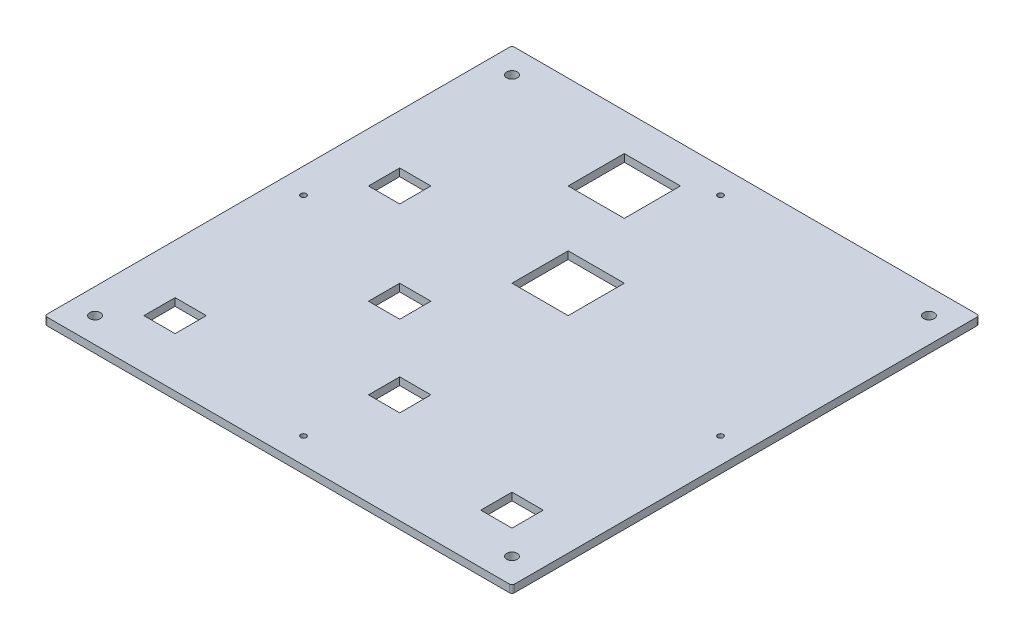
from build123d import *

# Parameters (mm, degrees)
ESQUISSE2_W             = 185
ESQUISSE2_H             = 185
BOSS_EXTRU_1_DEPTH      = 3
ESQUISSE3_W             = 185
ESQUISSE3_H             = 185
ESQUISSE3_W_2           = 155.54
ESQUISSE3_H_2           = 155.54
BOSS_EXTRU_2_DEPTH      = 40
BOSS_EXTRU_3_DEPTH      = 20
ENL_V_MAT_EXTRU_1_REACH = 5
ESQUISSE5_W             = 22.22
ESQUISSE5_H             = 22.22
ESQUISSE5_W_2           = 12.35
ESQUISSE5_H_2           = 12.35
CONG_1_R                = 1
ESQUISSE6_R             = 1.1
ENL_V_MAT_EXTRU_2_DEPTH = 44
ESQUISSE7_R             = 2.1
ENL_V_MAT_EXTRU_3_DEPTH = 44
ESQUISSE8_W             = 226.485362767
ESQUISSE8_H             = 93.740227698
ENL_V_MAT_EXTRU_4_DEPTH = 186


with BuildPart() as part:
    # Esquisse2 → Boss.-Extru.1 (new body)
    with BuildSketch(Plane(origin=(0, 0, 0), x_dir=(1, 0, 0), z_dir=(0, 1, 0))):
        Rectangle(ESQUISSE2_W, ESQUISSE2_H)
    extrude(amount=-BOSS_EXTRU_1_DEPTH)

    # Esquisse3 → Boss.-Extru.2 (add)
    with BuildSketch(Plane(origin=(0, 0, 0), x_dir=(1, 0, 0), z_dir=(0, 1, 0))):
        Rectangle(ESQUISSE3_W, ESQUISSE3_H)
        Rectangle(ESQUISSE3_W_2, ESQUISSE3_H_2, mode=Mode.SUBTRACT)
    extrude(amount=BOSS_EXTRU_2_DEPTH)

    # Esquisse4 → Boss.-Extru.3 (add)
    with BuildSketch(Plane(origin=(0, 0, 0), x_dir=(1, 0, 0), z_dir=(0, 1, 0))):
        Polygon((-55.55, 77.77), (-33.33, 77.77), (-33.33, 55.55), (11.11, 55.55), (11.11, 33.33), (-11.11, 33.33), (-11.11, -11.11), (-33.33, -11.11), (-33.33, -55.55), (-55.55, -55.55), (-55.55, 11.11), (-33.33, 11.11), (-33.33, 33.33), (-55.55, 33.33), align=None)
        Polygon((33.33, 55.55), (55.55, 55.55), (55.55, -55.55), (33.33, -55.55), (33.33, -77.77), (11.11, -77.77), (11.11, -33.33), (33.33, -33.33), align=None)
    extrude(amount=BOSS_EXTRU_3_DEPTH)

    # Esquisse5 → Enlèv. mat.-Extru.1 (cut, up to next)
    with BuildSketch(Plane(origin=(0, 0, 0), x_dir=(1, 0, 0), z_dir=(0, 1, 0)), mode=Mode.PRIVATE) as enl_v_mat_extru_1_sk1:
        with Locations((-22.22, 66.66)):
            Rectangle(ESQUISSE5_W, ESQUISSE5_H)
    enl_v_mat_extru_1_tool1 = extrude(enl_v_mat_extru_1_sk1.sketch, amount=-ENL_V_MAT_EXTRU_1_REACH, mode=Mode.PRIVATE) & part.part
    add(enl_v_mat_extru_1_tool1.solids().sort_by_distance((-22.22, 0, -66.66))[0], mode=Mode.SUBTRACT)
    # Esquisse5 → Enlèv. mat.-Extru.1 (cut, up to next)
    with BuildSketch(Plane(origin=(0, 0, 0), x_dir=(1, 0, 0), z_dir=(0, 1, 0)), mode=Mode.PRIVATE) as enl_v_mat_extru_1_sk2:
        with Locations((0, 22.22)):
            Rectangle(ESQUISSE5_W, ESQUISSE5_H)
    enl_v_mat_extru_1_tool2 = extrude(enl_v_mat_extru_1_sk2.sketch, amount=-ENL_V_MAT_EXTRU_1_REACH, mode=Mode.PRIVATE) & part.part
    add(enl_v_mat_extru_1_tool2.solids().sort_by_distance((0, 0, -22.22))[0], mode=Mode.SUBTRACT)
    # Esquisse5 → Enlèv. mat.-Extru.1 (cut, up to next)
    with BuildSketch(Plane(origin=(0, 0, 0), x_dir=(1, 0, 0), z_dir=(0, 1, 0)), mode=Mode.PRIVATE) as enl_v_mat_extru_1_sk3:
        with Locations((-27.155, -17.285)):
            Rectangle(ESQUISSE5_W_2, ESQUISSE5_H_2)
    enl_v_mat_extru_1_tool3 = extrude(enl_v_mat_extru_1_sk3.sketch, amount=-ENL_V_MAT_EXTRU_1_REACH, mode=Mode.PRIVATE) & part.part
    add(enl_v_mat_extru_1_tool3.solids().sort_by_distance((-27.155, 0, 17.285))[0], mode=Mode.SUBTRACT)
    # Esquisse5 → Enlèv. mat.-Extru.1 (cut, up to next)
    with BuildSketch(Plane(origin=(0, 0, 0), x_dir=(1, 0, 0), z_dir=(0, 1, 0)), mode=Mode.PRIVATE) as enl_v_mat_extru_1_sk4:
        with Locations((-66.66, 22.22)):
            Rectangle(ESQUISSE5_W_2, ESQUISSE5_H_2)
    enl_v_mat_extru_1_tool4 = extrude(enl_v_mat_extru_1_sk4.sketch, amount=-ENL_V_MAT_EXTRU_1_REACH, mode=Mode.PRIVATE) & part.part
    add(enl_v_mat_extru_1_tool4.solids().sort_by_distance((-66.66, 0, -22.22))[0], mode=Mode.SUBTRACT)
    # Esquisse5 → Enlèv. mat.-Extru.1 (cut, up to next)
    with BuildSketch(Plane(origin=(0, 0, 0), x_dir=(1, 0, 0), z_dir=(0, 1, 0)), mode=Mode.PRIVATE) as enl_v_mat_extru_1_sk5:
        with Locations((-66.66, -66.66)):
            Rectangle(ESQUISSE5_W_2, ESQUISSE5_H_2)
    enl_v_mat_extru_1_tool5 = extrude(enl_v_mat_extru_1_sk5.sketch, amount=-ENL_V_MAT_EXTRU_1_REACH, mode=Mode.PRIVATE) & part.part
    add(enl_v_mat_extru_1_tool5.solids().sort_by_distance((-66.66, 0, 66.66))[0], mode=Mode.SUBTRACT)
    # Esquisse5 → Enlèv. mat.-Extru.1 (cut, up to next)
    with BuildSketch(Plane(origin=(0, 0, 0), x_dir=(1, 0, 0), z_dir=(0, 1, 0)), mode=Mode.PRIVATE) as enl_v_mat_extru_1_sk6:
        with Locations((66.66, -66.66)):
            Rectangle(ESQUISSE5_W_2, ESQUISSE5_H_2)
    enl_v_mat_extru_1_tool6 = extrude(enl_v_mat_extru_1_sk6.sketch, amount=-ENL_V_MAT_EXTRU_1_REACH, mode=Mode.PRIVATE) & part.part
    add(enl_v_mat_extru_1_tool6.solids().sort_by_distance((66.66, 0, 66.66))[0], mode=Mode.SUBTRACT)
    # Esquisse5 → Enlèv. mat.-Extru.1 (cut, up to next)
    with BuildSketch(Plane(origin=(0, 0, 0), x_dir=(1, 0, 0), z_dir=(0, 1, 0)), mode=Mode.PRIVATE) as enl_v_mat_extru_1_sk7:
        with Locations((4.935, -49.375)):
            Rectangle(ESQUISSE5_W_2, ESQUISSE5_H_2)
    enl_v_mat_extru_1_tool7 = extrude(enl_v_mat_extru_1_sk7.sketch, amount=-ENL_V_MAT_EXTRU_1_REACH, mode=Mode.PRIVATE) & part.part
    add(enl_v_mat_extru_1_tool7.solids().sort_by_distance((4.935, 0, 49.375))[0], mode=Mode.SUBTRACT)

    # Congé1
    cong_1_edges = [part.edges().sort_by_distance(p)[0] for p in [
        (-92.5, 40, 0),
        (0, 40, 92.5),
        (92.5, 40, 0),
        (0, 40, -92.5),
        (-92.5, 18.5, -92.5),
        (92.5, 18.5, -92.5),
        (92.5, 18.5, 92.5),
        (-92.5, 18.5, 92.5),
    ]]
    fillet(cong_1_edges, radius=CONG_1_R)

    # Esquisse6 → Enlèv. mat.-Extru.2 (cut, through all)
    with BuildSketch(Plane(origin=(0, 40, 0), x_dir=(1, 0, 0), z_dir=(0, 1, 0))):
        with Locations(Location((-82.5, -82.5, 0), (0, 0, 270))):  # turned: the seam where the file's is
            Circle(ESQUISSE6_R)
        with Locations(Location((82.5, -82.5, 0), (0, 0, 270))):  # turned: the seam where the file's is
            Circle(ESQUISSE6_R)
        with Locations(Location((82.5, 82.5, 0), (0, 0, 270))):  # turned: the seam where the file's is
            Circle(ESQUISSE6_R)
        with Locations(Location((-82.5, 82.5, 0), (0, 0, 270))):  # turned: the seam where the file's is
            Circle(ESQUISSE6_R)
        with Locations(Location((0, 82.5, 0), (0, 0, 270))):  # turned: the seam where the file's is
            Circle(ESQUISSE6_R)
        with Locations(Location((-82.5, 0, 0), (0, 0, 270))):  # turned: the seam where the file's is
            Circle(ESQUISSE6_R)
        with Locations(Location((82.5, 0, 0), (0, 0, 270))):  # turned: the seam where the file's is
            Circle(ESQUISSE6_R)
        with Locations(Location((0, -82.5, 0), (0, 0, 270))):  # turned: the seam where the file's is
            Circle(ESQUISSE6_R)
    extrude(amount=-ENL_V_MAT_EXTRU_2_DEPTH, mode=Mode.SUBTRACT)

    # Esquisse7 → Enlèv. mat.-Extru.3 (cut, through all)
    with BuildSketch(Plane(origin=(0, 40, 0), x_dir=(1, 0, 0), z_dir=(0, 1, 0))):
        with Locations(Location((-82.5, -82.5, 0), (0, 0, 270))):  # turned: the seam where the file's is
            Circle(ESQUISSE7_R)
        with Locations(Location((-82.5, 82.5, 0), (0, 0, 270))):  # turned: the seam where the file's is
            Circle(ESQUISSE7_R)
        with Locations(Location((82.5, 82.5, 0), (0, 0, 270))):  # turned: the seam where the file's is
            Circle(ESQUISSE7_R)
        with Locations(Location((82.5, -82.5, 0), (0, 0, 270))):  # turned: the seam where the file's is
            Circle(ESQUISSE7_R)
    extrude(amount=-ENL_V_MAT_EXTRU_3_DEPTH, mode=Mode.SUBTRACT)

    # Esquisse8 → Enlèv. mat.-Extru.4 (cut, through all)
    with BuildSketch(Plane.XY.offset(92.5)):
        with Locations((0.829347629, 46.870113849)):
            Rectangle(ESQUISSE8_W, ESQUISSE8_H)
    extrude(amount=-ENL_V_MAT_EXTRU_4_DEPTH, mode=Mode.SUBTRACT)


solid = part.part
